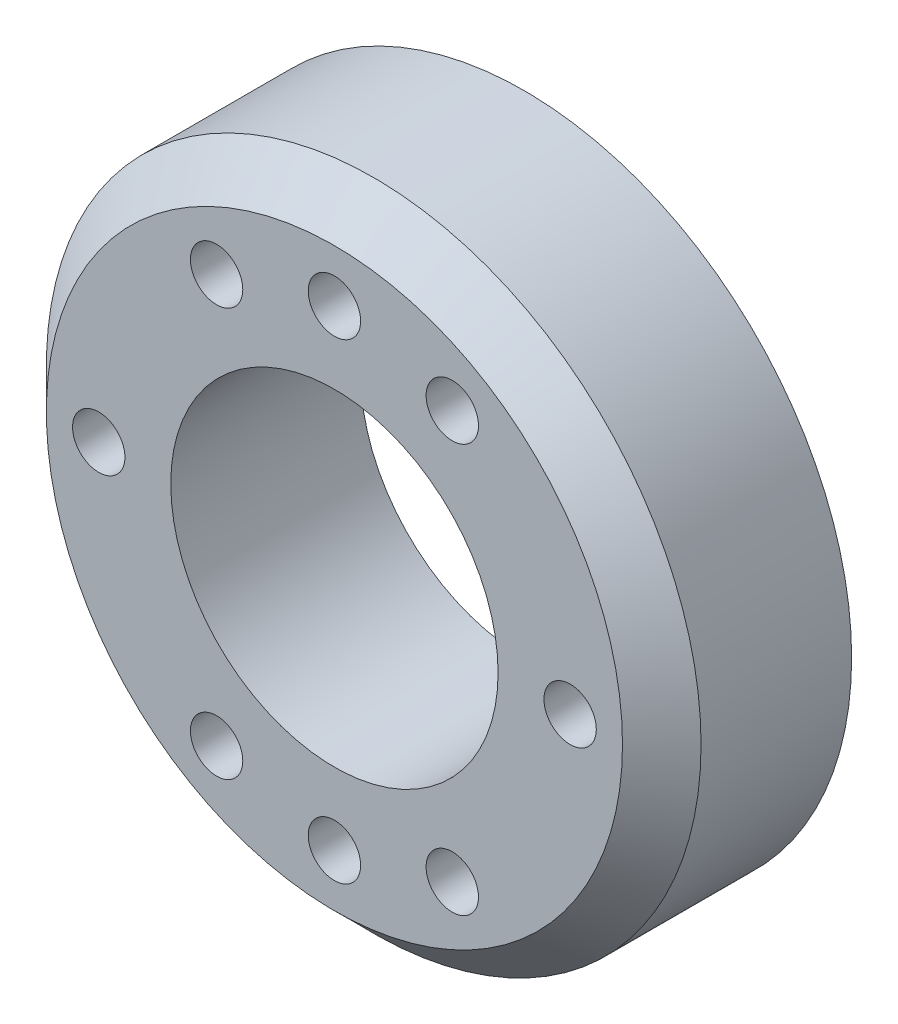
from build123d import *

# Parameters (mm, degrees)
SKETCH1_R           = 25
SKETCH1_R_2         = 12.5
SKETCH1_R_3         = 2
BOSS_EXTRUDE1_DEPTH = 14.5
CHAMFER1_SIZE       = 3


with BuildPart() as part:
    # Sketch1 → Boss-Extrude1 (new body)
    with BuildSketch(Plane.XY):
        Circle(SKETCH1_R)
        Circle(SKETCH1_R_2, mode=Mode.SUBTRACT)
        with Locations((0, 18)):
            Circle(SKETCH1_R_3, mode=Mode.SUBTRACT)
        with Locations((9, 15.588457268)):
            Circle(SKETCH1_R_3, mode=Mode.SUBTRACT)
        with Locations((18, 0)):
            Circle(SKETCH1_R_3, mode=Mode.SUBTRACT)
        with Locations((9, -15.588457268)):
            Circle(SKETCH1_R_3, mode=Mode.SUBTRACT)
        with Locations((0, -18)):
            Circle(SKETCH1_R_3, mode=Mode.SUBTRACT)
        with Locations((-9, -15.588457268)):
            Circle(SKETCH1_R_3, mode=Mode.SUBTRACT)
        with Locations((-18, 0)):
            Circle(SKETCH1_R_3, mode=Mode.SUBTRACT)
        with Locations((-9, 15.588457268)):
            Circle(SKETCH1_R_3, mode=Mode.SUBTRACT)
    extrude(amount=BOSS_EXTRUDE1_DEPTH)

    # Chamfer1
    chamfer1_edges = [part.edges().sort_by_distance(p)[0] for p in [
        (-25, 0, 14.5),
    ]]
    chamfer(chamfer1_edges, length=CHAMFER1_SIZE)


solid = part.part
